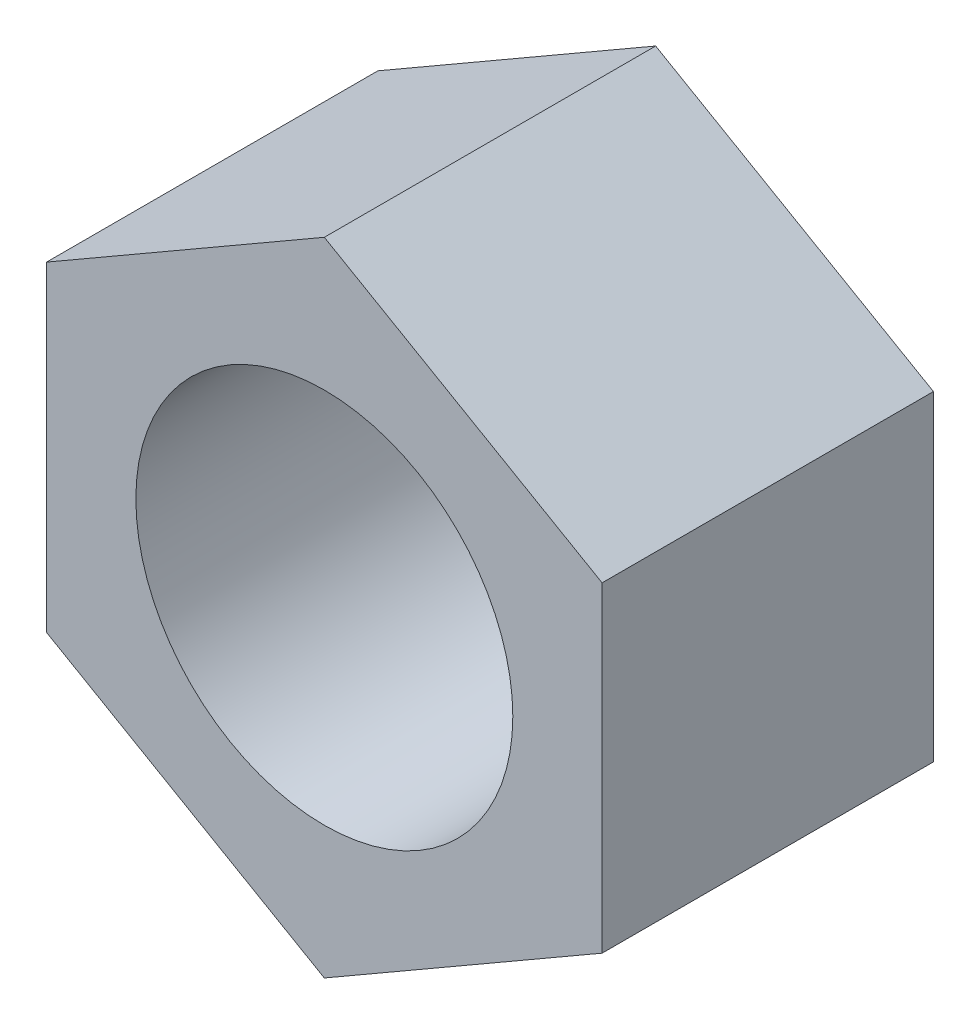
from build123d import *

# Parameters (mm, degrees)
SKETCH1_R           = 4.75
BOSS_EXTRUDE1_DEPTH = 8.35


with BuildPart() as part:
    # Sketch1 → Boss-Extrude1 (new body)
    with BuildSketch(Plane.XY):
        Polygon((7, 4.041451884), (0, 8.082903769), (-7, 4.041451884), (-7, -4.041451884), (0, -8.082903769), (7, -4.041451884), align=None)
        Circle(SKETCH1_R, mode=Mode.SUBTRACT)
    extrude(amount=BOSS_EXTRUDE1_DEPTH)


solid = part.part
